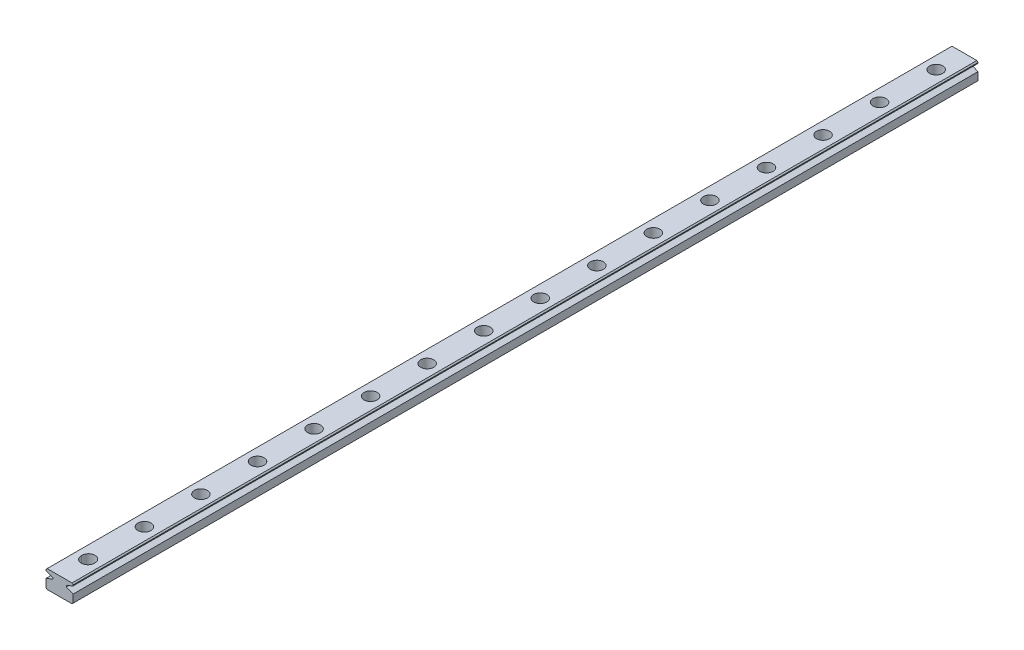
from build123d import *

# Parameters (mm, degrees)
EXTRUDE_1_DEPTH           = 400
HOLE_WIZARD_4_D           = 3.5
HOLE_WIZARD_4_CBORE_D     = 5.8
HOLE_WIZARD_4_CBORE_DEPTH = 4.5
HOLE_WIZARD_3_D           = 3.5
HOLE_WIZARD_3_DEPTH       = 7.916912277
HOLE_WIZARD_3_CBORE_D     = 5.8
HOLE_WIZARD_3_CBORE_DEPTH = 4.5


with BuildPart() as part:
    # 草图1 → 凸台-拉伸1 (new body)
    with BuildSketch(Plane.XY):
        Polygon((5.617628384, 4.221881307), (16.617628384, 4.221881307), (17.117628384, 4.721881307), (17.117628384, 8.221881307), (14.117628384, 9.445409037), (14.117628384, 9.987809251), (17.117628384, 11.343384147), (17.117628384, 11.721881307), (16.617628384, 12.221881307), (5.617628384, 12.221881307), (5.117628384, 11.721881307), (5.117628384, 11.211336981), (8.117628384, 9.987809251), (8.117628384, 9.445409037), (5.117628384, 8.221881307), (5.117628384, 4.721881307), align=None)
    extrude(amount=EXTRUDE_1_DEPTH)

    # 孔4 (through all)
    with Locations(Plane(origin=(11.117628384, 12.221881307, 387.5), x_dir=(0, 0, 1), z_dir=(0, 1, 0))):
        with Locations((0, 0), (-25, 0), (-49.975489716, 0), (-75, 0), (-100, 0), (-125.000497417, 0), (-150, 0), (-175, 0), (-200, 0), (-225, 0), (-250, 0), (-275, 0), (-300, 0), (-325, 0), (-350, 0), (-375, 0)):
            CounterBoreHole(HOLE_WIZARD_4_D / 2, HOLE_WIZARD_4_CBORE_D / 2, HOLE_WIZARD_4_CBORE_DEPTH)

    # 孔3
    with Locations(Plane(origin=(11.117628384, 12.221881307, 387.223861755), x_dir=(0, 0, 1), z_dir=(0, 1, 0))):
        with Locations((0, 0)):
            CounterBoreHole(HOLE_WIZARD_3_D / 2, HOLE_WIZARD_3_CBORE_D / 2, HOLE_WIZARD_3_CBORE_DEPTH, depth=HOLE_WIZARD_3_DEPTH)


solid = part.part
